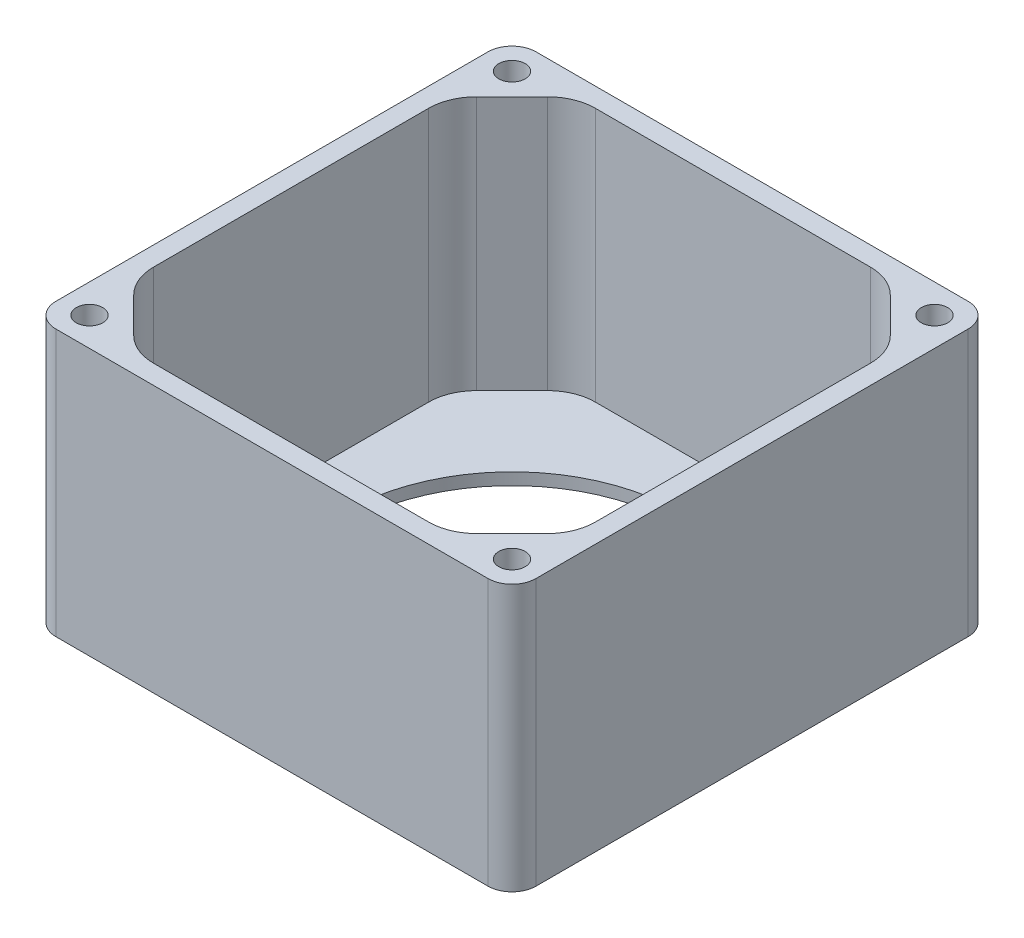
from build123d import *

# Parameters (mm, degrees)
SKETCH1_R                     = 44.45
SKETCH1_R_2                   = 3.25
BOSS_EXTRUDE1_DEPTH           = 3.175
BOSS_EXTRUDE2_DEPTH           = 67.31
CBORE_FOR_M6_SHCS2_AT_2_COUNT = 2
CBORE_FOR_M6_SHCS2_AT_2_PITCH = 111.76
CBORE_FOR_M6_SHCS2_AT_3_COUNT = 2
CBORE_FOR_M6_SHCS2_AT_3_PITCH = 158.052507731
CBORE_FOR_M6_SHCS2_AT_4_COUNT = 2
CBORE_FOR_M6_SHCS2_AT_4_PITCH = 111.76


with BuildPart() as part:
    # Sketch1 → Boss-Extrude1 (new body)
    with BuildSketch(Plane(origin=(0, 0, 0), x_dir=(1, 0, 0), z_dir=(0, 1, 0))):
        with BuildLine():
            Line((-57.15, 63.5), (57.15, 63.5))
            ThreePointArc((57.15, 63.5), (61.640128061, 61.640128061), (63.5, 57.15))
            Line((63.5, 57.15), (63.5, -57.15))
            ThreePointArc((63.5, -57.15), (61.640128061, -61.640128061), (57.15, -63.5))
            Line((57.15, -63.5), (-57.15, -63.5))
            ThreePointArc((-57.15, -63.5), (-61.640128061, -61.640128061), (-63.5, -57.15))
            Line((-63.5, -57.15), (-63.5, 57.15))
            ThreePointArc((-63.5, 57.15), (-61.640128061, 61.640128061), (-57.15, 63.5))
        make_face()
        Circle(SKETCH1_R, mode=Mode.SUBTRACT)
        with Locations((-57.15, 53.975)):
            Circle(SKETCH1_R_2, mode=Mode.SUBTRACT)
        with Locations((57.15, 53.975)):
            Circle(SKETCH1_R_2, mode=Mode.SUBTRACT)
        with Locations((57.15, -53.975)):
            Circle(SKETCH1_R_2, mode=Mode.SUBTRACT)
        with Locations((-57.15, -53.975)):
            Circle(SKETCH1_R_2, mode=Mode.SUBTRACT)
    extrude(amount=BOSS_EXTRUDE1_DEPTH)

    # Sketch3 → Boss-Extrude2 (add)
    with BuildSketch(Plane(origin=(0, 3.175, 0), x_dir=(1, 0, 0), z_dir=(0, 1, 0))):
        with BuildLine():
            Line((-57.15, -63.5), (57.15, -63.5))
            ThreePointArc((57.15, -63.5), (61.640128061, -61.640128061), (63.5, -57.15))
            Line((63.5, -57.15), (63.5, 57.15))
            ThreePointArc((63.5, 57.15), (61.640128061, 61.640128061), (57.15, 63.5))
            Line((57.15, 63.5), (-57.15, 63.5))
            ThreePointArc((-57.15, 63.5), (-61.640128061, 61.640128061), (-63.5, 57.15))
            Line((-63.5, 57.15), (-63.5, -57.15))
            ThreePointArc((-63.5, -57.15), (-61.640128061, -61.640128061), (-57.15, -63.5))
        make_face()
        with BuildLine():
            Line((-54.700256121, 45.358975516), (-45.358975516, 54.700256121))
            ThreePointArc((-45.358975516, 54.700256121), (-41.238798986, 57.453270063), (-36.378719395, 58.42))
            Line((-36.378719395, 58.42), (36.378719395, 58.42))
            ThreePointArc((36.378719395, 58.42), (41.238798986, 57.453270063), (45.358975516, 54.700256121))
            Line((45.358975516, 54.700256121), (54.700256121, 45.358975516))
            ThreePointArc((54.700256121, 45.358975516), (57.453270063, 41.238798986), (58.42, 36.378719395))
            Line((58.42, 36.378719395), (58.42, -36.378719395))
            ThreePointArc((58.42, -36.378719395), (57.453270063, -41.238798986), (54.700256121, -45.358975516))
            Line((54.700256121, -45.358975516), (45.358975516, -54.700256121))
            ThreePointArc((45.358975516, -54.700256121), (41.238798986, -57.453270063), (36.378719395, -58.42))
            Line((36.378719395, -58.42), (-36.378719395, -58.42))
            ThreePointArc((-36.378719395, -58.42), (-41.238798986, -57.453270063), (-45.358975516, -54.700256121))
            Line((-45.358975516, -54.700256121), (-54.700256121, -45.358975516))
            ThreePointArc((-54.700256121, -45.358975516), (-57.453270063, -41.238798986), (-58.42, -36.378719395))
            Line((-58.42, -36.378719395), (-58.42, 36.378719395))
            ThreePointArc((-58.42, 36.378719395), (-57.453270063, 41.238798986), (-54.700256121, 45.358975516))
        make_face(mode=Mode.SUBTRACT)
    extrude(amount=BOSS_EXTRUDE2_DEPTH)

    # Sketch9 → CBORE for M6 SHCS2 (revolve, cut)
    with BuildSketch(Plane(origin=(55.88, 0, -55.88), x_dir=(0, 0, -1), z_dir=(1, 0, 0))):
        Polygon((0, 0), (0, 70.485), (3.5, 70.485), (3.5, 31.4), (5.5, 31.4), (5.5, 0.025), (5.525, 0), align=None)
    cbore_for_m6_shcs2 = revolve(axis=Axis((55.88, -6.35, -55.88), (0, 1, 0)), mode=Mode.SUBTRACT)

    # CBORE for M6 SHCS2 at 2: CBORE for M6 SHCS2 ×2
    with Locations(*[(-i * CBORE_FOR_M6_SHCS2_AT_2_PITCH, 0, 0) for i in range(1, CBORE_FOR_M6_SHCS2_AT_2_COUNT)]):
        add(cbore_for_m6_shcs2, mode=Mode.SUBTRACT)

    # CBORE for M6 SHCS2 at 3: CBORE for M6 SHCS2 ×2
    with Locations(*[Vector(-0.707106781, 0, 0.707106781) * (i * CBORE_FOR_M6_SHCS2_AT_3_PITCH) for i in range(1, CBORE_FOR_M6_SHCS2_AT_3_COUNT)]):
        add(cbore_for_m6_shcs2, mode=Mode.SUBTRACT)

    # CBORE for M6 SHCS2 at 4: CBORE for M6 SHCS2 ×2
    with Locations(*[(0, 0, i * CBORE_FOR_M6_SHCS2_AT_4_PITCH) for i in range(1, CBORE_FOR_M6_SHCS2_AT_4_COUNT)]):
        add(cbore_for_m6_shcs2, mode=Mode.SUBTRACT)


solid = part.part
